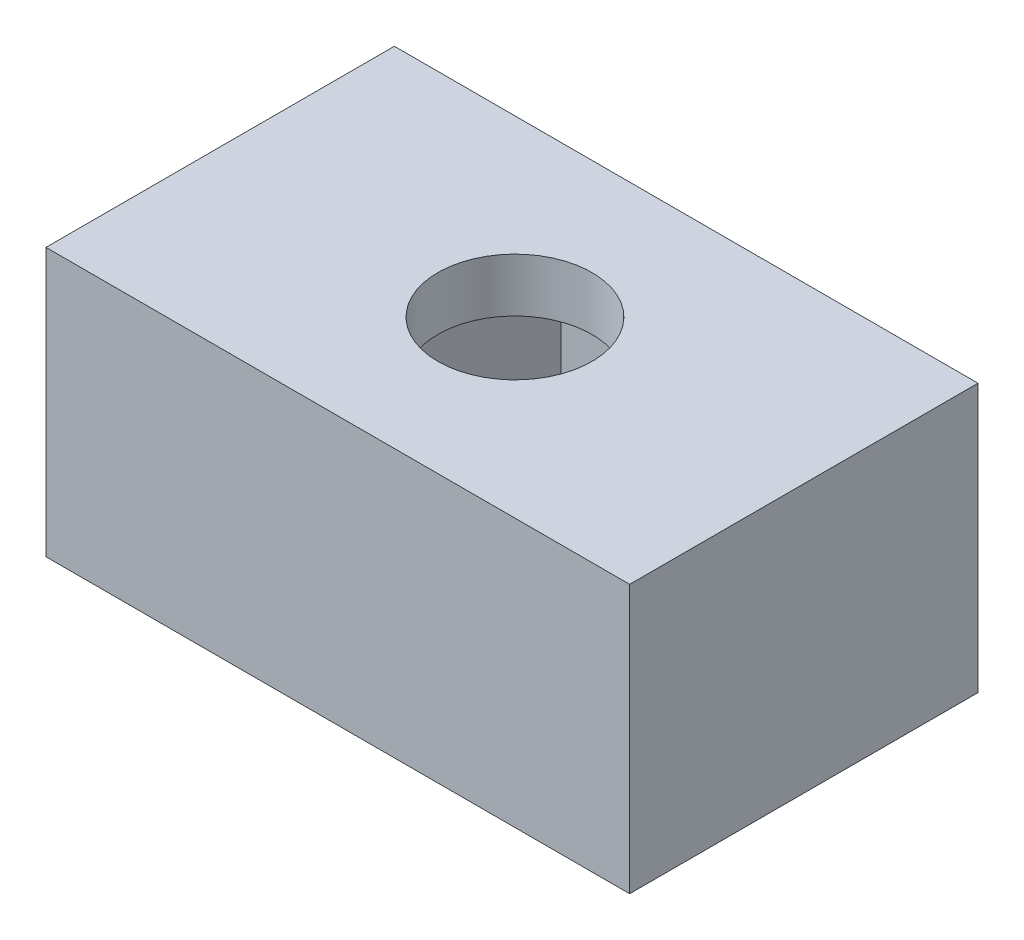
from build123d import *

# Parameters (mm, degrees)
CROQUIS1_W              = 54
CROQUIS1_H              = 13
SALIENTE_EXTRUIR1_DEPTH = 10
CORTAR_EXTRUIR1_DEPTH   = 8
CROQUIS1_4_R            = 2.875
CORTAR_EXTRUIR2_DEPTH   = 30.516944286
CROQUIS2_W              = 50.887178886
CROQUIS2_H              = 27.662521268
CORTAR_EXTRUIR3_DEPTH   = 35.356635458


with BuildPart() as part:
    # Croquis1 → Saliente-Extruir1 (new body)
    with BuildSketch(Plane(origin=(0, 0, 0), x_dir=(1, 0, 0), z_dir=(0, 1, 0))):
        Rectangle(CROQUIS1_W, CROQUIS1_H)
    extrude(amount=SALIENTE_EXTRUIR1_DEPTH)

    # Croquis1_3 → Cortar-Extruir1 (cut)
    with BuildSketch(Plane(origin=(0, 0, 0), x_dir=(1, 0, 0), z_dir=(0, 1, 0))):
        Polygon((-18.33826859, -4.05), (-13.66173141, -4.05), (-11.32346282, 0), (-13.66173141, 4.05), (-18.33826859, 4.05), (-20.67653718, 0), align=None)
        Polygon((20.67653718, 0), (18.33826859, 4.05), (13.66173141, 4.05), (11.32346282, 0), (13.66173141, -4.05), (18.33826859, -4.05), align=None)
    extrude(amount=CORTAR_EXTRUIR1_DEPTH, mode=Mode.SUBTRACT)

    # Croquis1_4 → Cortar-Extruir2 (cut, through all)
    with BuildSketch(Plane(origin=(0, 0, 0), x_dir=(1, 0, 0), z_dir=(0, 1, 0))):
        with Locations((-16, 0)):
            Circle(CROQUIS1_4_R)
        with Locations((16, 0)):
            Circle(CROQUIS1_4_R)
    extrude(amount=CORTAR_EXTRUIR2_DEPTH, mode=Mode.SUBTRACT)

    # Croquis2 → Cortar-Extruir3 (cut, through all)
    with BuildSketch(Plane.ZY.offset(5.22)):
        with Locations((0.866942471, 5.460502056)):
            Rectangle(CROQUIS2_W, CROQUIS2_H)
    extrude(amount=-CORTAR_EXTRUIR3_DEPTH, mode=Mode.SUBTRACT)


solid = part.part
